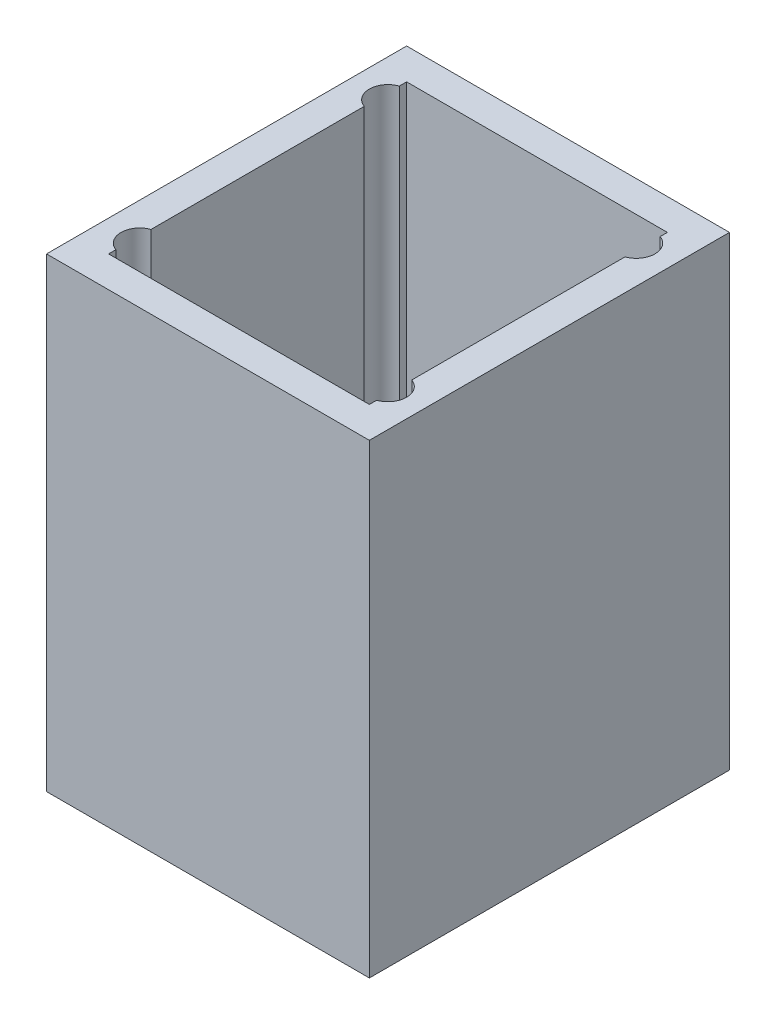
from build123d import *

# Parameters (mm, degrees)
SKETCH1_W           = 52
SKETCH1_H           = 58
SKETCH1_R           = 1.7
BOSS_EXTRUDE1_DEPTH = 2
SKETCH2_W           = 52
SKETCH2_H           = 58
SKETCH2_R           = 3
BOSS_EXTRUDE2_DEPTH = 3
SKETCH3_W           = 52
SKETCH3_H           = 58
BOSS_EXTRUDE3_DEPTH = 70


with BuildPart() as part:
    # Sketch1 → Boss-Extrude1 (new body)
    with BuildSketch(Plane(origin=(0, 0, 0), x_dir=(1, 0, 0), z_dir=(0, 1, 0))):
        Rectangle(SKETCH1_W, SKETCH1_H)
        with Locations((-20, 20)):
            Circle(SKETCH1_R, mode=Mode.SUBTRACT)
        with Locations((-20, -20)):
            Circle(SKETCH1_R, mode=Mode.SUBTRACT)
        with Locations((20, -20)):
            Circle(SKETCH1_R, mode=Mode.SUBTRACT)
        with Locations((20, 20)):
            Circle(SKETCH1_R, mode=Mode.SUBTRACT)
    extrude(amount=BOSS_EXTRUDE1_DEPTH)

    # Sketch2 → Boss-Extrude2 (add)
    with BuildSketch(Plane(origin=(0, 2, 0), x_dir=(1, 0, 0), z_dir=(0, 1, 0))):
        Rectangle(SKETCH2_W, SKETCH2_H)
        with Locations((-20, 20)):
            Circle(SKETCH2_R, mode=Mode.SUBTRACT)
        with Locations((-20, -20)):
            Circle(SKETCH2_R, mode=Mode.SUBTRACT)
        with Locations((20, 20)):
            Circle(SKETCH2_R, mode=Mode.SUBTRACT)
        with Locations((20, -20)):
            Circle(SKETCH2_R, mode=Mode.SUBTRACT)
    extrude(amount=BOSS_EXTRUDE2_DEPTH)

    # Sketch3 → Boss-Extrude3 (add)
    with BuildSketch(Plane(origin=(0, 5, 0), x_dir=(1, 0, 0), z_dir=(0, 1, 0))):
        Rectangle(SKETCH3_W, SKETCH3_H)
        with BuildLine():
            Line((-21, 22.828427125), (-21, 24))
            Line((-21, 24), (21, 24))
            Line((21, 24), (21, 22.828427125))
            ThreePointArc((21, 22.828427125), (22.449489743, 21.732050808), (23, 20))
            ThreePointArc((23, 20), (22.449489743, 18.267949192), (21, 17.171572875))
            Line((21, 17.171572875), (21, -17.171572875))
            ThreePointArc((21, -17.171572875), (22.449489743, -18.267949192), (23, -20))
            ThreePointArc((23, -20), (22.449489743, -21.732050808), (21, -22.828427125))
            Line((21, -22.828427125), (21, -24))
            Line((21, -24), (-21, -24))
            Line((-21, -24), (-21, -22.828427125))
            ThreePointArc((-21, -22.828427125), (-23, -20), (-21, -17.171572875))
            Line((-21, -17.171572875), (-21, 17.171572875))
            ThreePointArc((-21, 17.171572875), (-23, 20), (-21, 22.828427125))
        make_face(mode=Mode.SUBTRACT)
    extrude(amount=BOSS_EXTRUDE3_DEPTH)


solid = part.part
